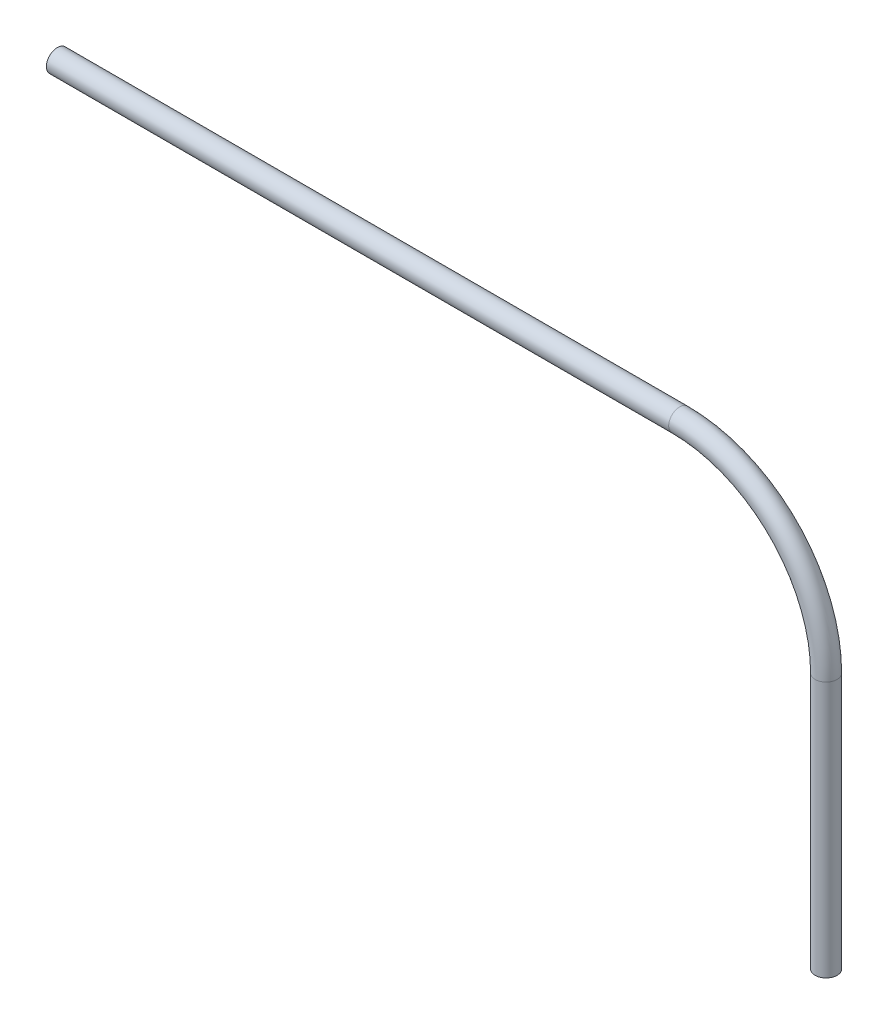
from build123d import *

# Parameters (mm, degrees)
SWEEP_THIN1_PROFILE_R   = 30
SWEEP_THIN1_PROFILE_R_2 = 27


with BuildPart() as part:
    # Sweep-Thin1: sweep along a path in Sketch1
    with BuildLine(Plane.XY) as sweep_thin1_path:
        Line((4624.960176957, -100), (4624.960176957, 600))
        ThreePointArc((4624.960176957, 600), (4507.802889432, 882.842712475), (4224.960176957, 1000))
        Line((4224.960176957, 1000), (2524.960176957, 1000))
    # Sweep-Thin1 profile (on start of the path) → Sweep-Thin1 (sweep)
    with BuildSketch(Plane(origin=(4624.960176957, -100, 0), x_dir=(0, 0, 1), z_dir=(0, 1, 0))):
        Circle(SWEEP_THIN1_PROFILE_R)
        Circle(SWEEP_THIN1_PROFILE_R_2, mode=Mode.SUBTRACT)
    sweep(path=sweep_thin1_path.line)


solid = part.part
